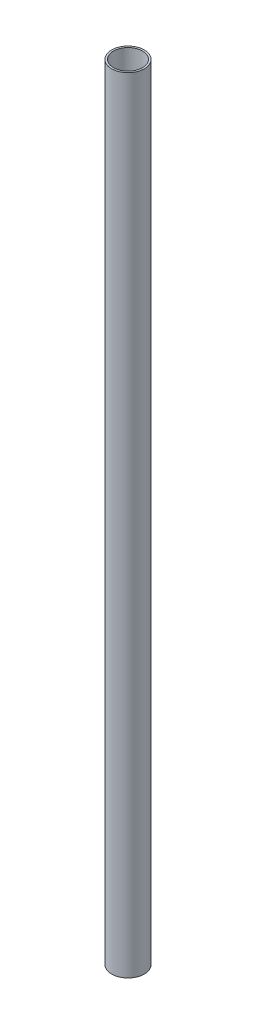
from build123d import *

# Parameters (mm, degrees)
SKETCH1_R           = 6.35
SKETCH1_R_2         = 5.6388
BOSS_EXTRUDE1_DEPTH = 304.8


with BuildPart() as part:
    # Sketch1 → Boss-Extrude1 (new body)
    with BuildSketch(Plane(origin=(0, 0, 0), x_dir=(1, 0, 0), z_dir=(0, 1, 0))):
        Circle(SKETCH1_R)
        Circle(SKETCH1_R_2, mode=Mode.SUBTRACT)
    extrude(amount=BOSS_EXTRUDE1_DEPTH)


solid = part.part
